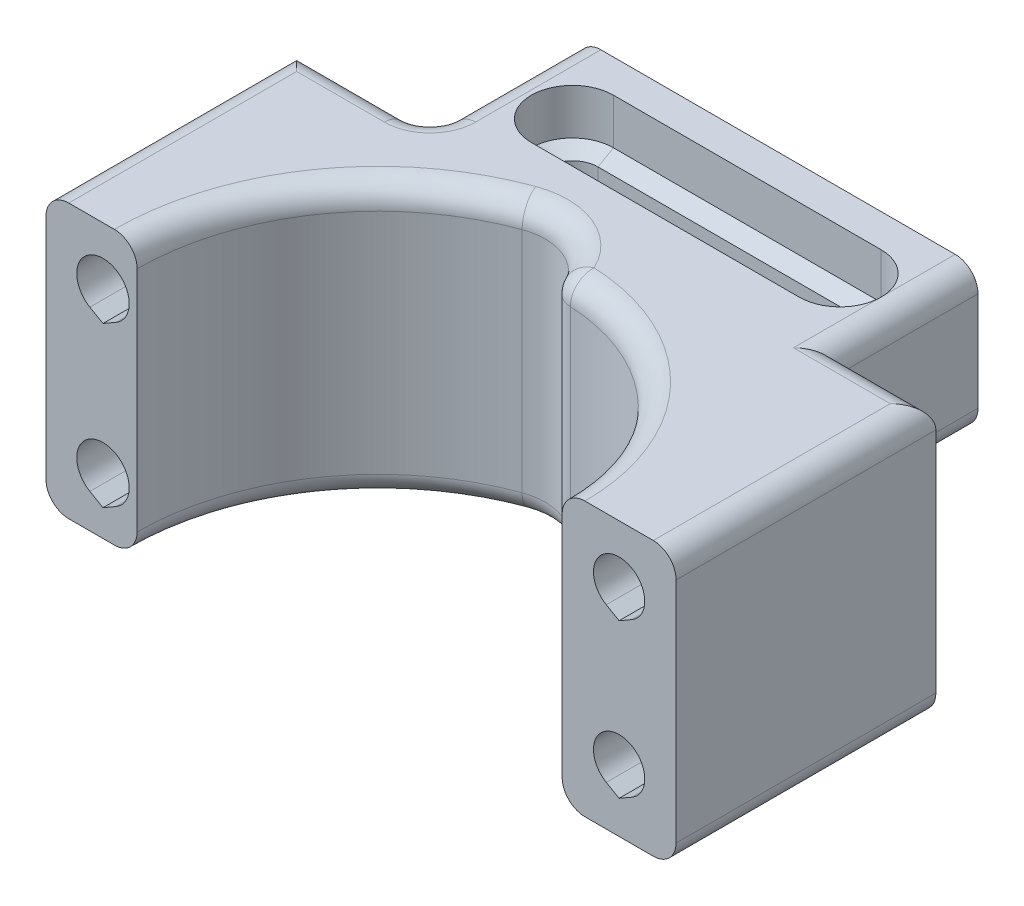
from build123d import *

# Parameters (mm, degrees)
AUFSATZ_LINEAR_AUSTRAGEN1_DEPTH = 24
VERRUNDUNG1_R                   = 2
SKIZZE6_R                       = 2.3
SCHNITT_LINEAR_AUSTRAGEN2_DEPTH = 100
SKIZZE7_W                       = 12.2
SKIZZE7_H                       = 11.3
SCHNITT_LINEAR_AUSTRAGEN3_DEPTH = 56.3
SCHNITT_LINEAR_AUSTRAGEN4_DEPTH = 25
SCHNITT_LINEAR_AUSTRAGEN5_DEPTH = 13.7
VERRUNDUNG2_R                   = 2
SCHNITT_LINEAR_AUSTRAGEN6_DEPTH = 23.5


with BuildPart() as part:
    # Skizze1 → Aufsatz-Linear austragen1 (new body)
    with BuildSketch(Plane(origin=(0, 0, 0), x_dir=(1, 0, 0), z_dir=(0, 1, 0))):
        with BuildLine():
            Line((-29.15, 22), (-29.15, 0))
            Line((-29.15, 0), (-21.15, 0))
            ThreePointArc((-21.15, 0), (-17.325065737, 12.131141629), (-7.233726031, 19.87449893))
            ThreePointArc((-7.233726031, 19.87449893), (-3.065111361, 19.529851295), (-0.617075906, 16.138206757))
            ThreePointArc((-0.617075906, 16.138206757), (11.199480437, 11.635898674), (16.15, 0))
            Line((16.15, 0), (26.15, 0))
            Line((26.15, 0), (26.15, 22.8))
            Line((26.15, 22.8), (17.65, 22.8))
            Line((17.65, 22.8), (17.65, 35))
            Line((17.65, 35), (-17.45, 35))
            Line((-17.45, 35), (-17.45, 22))
            Line((-17.45, 22), (-29.15, 22))
        make_face()
    extrude(amount=AUFSATZ_LINEAR_AUSTRAGEN1_DEPTH)

    # Verrundung1
    verrundung1_edges = [part.edges().sort_by_distance(p)[0] for p in [
        (-17.45, 12, -22),
    ]]
    fillet(verrundung1_edges, radius=VERRUNDUNG1_R)

    # Skizze6 → Schnitt-Linear austragen2 (cut)
    with BuildSketch(Plane.XY):
        with Locations((-24.15, 19)):
            Circle(SKIZZE6_R)
        with Locations((-24.15, 5)):
            Circle(SKIZZE6_R)
        with BuildLine():
            Line((-25.3, 17.008141571), (-24.15, 16.344188762))
            Line((-24.15, 16.344188762), (-23, 17.008141571))
            ThreePointArc((-23, 17.008141571), (-24.15, 16.7), (-25.3, 17.008141571))
        make_face()
        with BuildLine():
            Line((-25.3, 3.008141571), (-24.15, 2.344188762))
            Line((-24.15, 2.344188762), (-23, 3.008141571))
            ThreePointArc((-23, 3.008141571), (-24.15, 2.7), (-25.3, 3.008141571))
        make_face()
    extrude(amount=-SCHNITT_LINEAR_AUSTRAGEN2_DEPTH, mode=Mode.SUBTRACT)

    # Skizze7 → Schnitt-Linear austragen3 (cut, through all)
    with BuildSketch(Plane(origin=(26.15, 0, 0), x_dir=(0, 0, -1), z_dir=(1, 0, 0))):
        with Locations((28.9, 5.65)):
            Rectangle(SKIZZE7_W, SKIZZE7_H)
    extrude(amount=-SCHNITT_LINEAR_AUSTRAGEN3_DEPTH, mode=Mode.SUBTRACT)

    # Skizze8 → Schnitt-Linear austragen4 (cut)
    with BuildSketch(Plane(origin=(0, 0, -22.8), x_dir=(-1, 0, 0), z_dir=(0, 0, -1))):
        with BuildLine():
            Line((-22.275, 3.551442841), (-21.15, 2.901923789))
            Line((-21.15, 2.901923789), (-20.025, 3.551442841))
            ThreePointArc((-20.025, 3.551442841), (-21.15, 7.75), (-22.275, 3.551442841))
        make_face()
        with BuildLine():
            Line((-22.275, 17.051442841), (-21.15, 16.401923789))
            Line((-21.15, 16.401923789), (-20.025, 17.051442841))
            ThreePointArc((-20.025, 17.051442841), (-21.15, 21.25), (-22.275, 17.051442841))
        make_face()
    extrude(amount=-SCHNITT_LINEAR_AUSTRAGEN4_DEPTH, mode=Mode.SUBTRACT)

    # Skizze10 → Schnitt-Linear austragen5 (cut, through all)
    with BuildSketch(Plane.XZ.offset(-11.3)):
        with BuildLine():
            Line((-11.45, -26.25), (12.05, -26.25))
            ThreePointArc((12.05, -26.25), (14.3, -28.5), (12.05, -30.75))
            Line((12.05, -30.75), (-11.45, -30.75))
            ThreePointArc((-11.45, -30.75), (-13.7, -28.5), (-11.45, -26.25))
        make_face()
    extrude(amount=-SCHNITT_LINEAR_AUSTRAGEN5_DEPTH, mode=Mode.SUBTRACT)

    # Verrundung2
    verrundung2_edges = [part.edges().sort_by_distance(p)[0] for p in [
        (-3.065111361, 24, -19.529851295),
        (-29.15, 0, -11),
        (11.199480437, 24, -11.635898674),
        (26.15, 0, -11.4),
        (11.199480437, 0, -11.635898674),
        (-3.065111361, 0, -19.529851295),
        (-17.325065737, 0, -12.131141629),
        (-0.617075906, 12, -16.138206757),
        (26.15, 24, -11.4),
        (21.9, 24, -22.8),
        (17.65, 24, -28.9),
        (-17.45, 24, -29.5),
        (-18.035786438, 24, -22.585786438),
        (-24.3, 24, -22),
        (-29.15, 24, -11),
        (-17.325065737, 24, -12.131141629),
        (-17.552633404, 11.3, -23.367544468),
        (17.65, 11.3, -28.9),
        (-17.45, 11.3, -29.5),
    ]]
    fillet(verrundung2_edges, radius=VERRUNDUNG2_R)

    # Skizze12 → Schnitt-Linear austragen6 (cut)
    with BuildSketch(Plane(origin=(-11.45, 0, 0), x_dir=(0, 0, -1), z_dir=(1, 0, 0))):
        Polygon((24.9, 24), (24.9, 20), (26.25, 19.220577137), (30.75, 19.220577137), (32.1, 20), (32.1, 24), align=None)
    extrude(amount=SCHNITT_LINEAR_AUSTRAGEN6_DEPTH, mode=Mode.SUBTRACT)

    # Skizze12_3 one side → Schnitt-Rotation1 (revolve, cut)
    with BuildSketch(Plane(origin=(-11.45, 0, 0), x_dir=(0, 0, -1), z_dir=(1, 0, 0))):
        Polygon((32.1, 24), (28.5, 24), (28.5, 19.220577137), (30.75, 19.220577137), (32.1, 20), align=None)
    schnitt_rotation1 = revolve(axis=Axis((-11.45, 24, -28.5), (0, -1, 0)), mode=Mode.SUBTRACT)

    # Spiegeln1: Schnitt-Rotation1 across plane
    add(schnitt_rotation1.mirror(Plane.ZY.offset(-0.3)), mode=Mode.SUBTRACT)


solid = part.part
